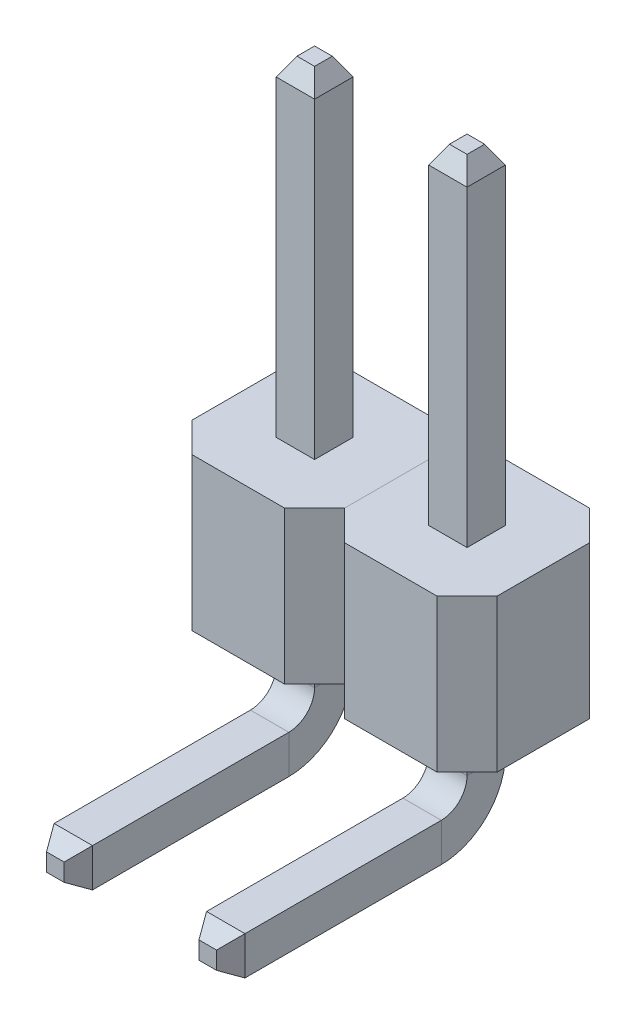
from build123d import *

# Parameters (mm, degrees)
SKETCH1_W             = 2.54
SKETCH1_H             = 2.54
BOSS_EXTRUDE1_DEPTH   = 2.54
CHAMFER1_SIZE         = 0.5
SKETCH3_W             = 0.64
SKETCH3_H             = 0.64
CHAMFER2_SIZE         = 0.3
CHAMFER2_SIZE2        = 0.173205081
CHAMFER2_PART_2_SIZE  = 0.3
CHAMFER2_PART_2_SIZE2 = 0.173205081
CHAMFER2_PART_3_SIZE  = 0.3
CHAMFER2_PART_3_SIZE2 = 0.173205081
CHAMFER2_PART_4_SIZE  = 0.3
CHAMFER2_PART_4_SIZE2 = 0.173205081
CHAMFER2_PART_5_SIZE  = 0.3
CHAMFER2_PART_5_SIZE2 = 0.173205081
CHAMFER2_PART_6_SIZE  = 0.3
CHAMFER2_PART_6_SIZE2 = 0.173205081
CHAMFER2_PART_7_SIZE  = 0.3
CHAMFER2_PART_7_SIZE2 = 0.173205081
CHAMFER2_PART_8_SIZE  = 0.3
CHAMFER2_PART_8_SIZE2 = 0.173205081
LPATTERN1_COUNT       = 2
LPATTERN1_PITCH       = 2.54


with BuildPart() as part:
    # Sketch1 → Boss-Extrude1 (new body)
    with BuildSketch(Plane(origin=(0, 0, 0), x_dir=(1, 0, 0), z_dir=(0, 1, 0))):
        Rectangle(SKETCH1_W, SKETCH1_H)
    extrude(amount=BOSS_EXTRUDE1_DEPTH)

    # Chamfer1
    chamfer1_edges = [part.edges().sort_by_distance(p)[0] for p in [
        (1.27, 1.27, 1.27),
        (-1.27, 1.27, 1.27),
        (-1.27, 1.27, -1.27),
        (1.27, 1.27, -1.27),
    ]]
    chamfer(chamfer1_edges, length=CHAMFER1_SIZE)

    # Sweep1: sweep along a path in Sketch2
    with BuildLine(Plane(origin=(0, 0, 0), x_dir=(0, 0, -1), z_dir=(1, 0, 0))) as sweep1_path:
        Line((0, 8.04), (0, -0.75))
        ThreePointArc((0, -0.75), (-0.219669914, -1.280330086), (-0.75, -1.5))
        Line((-0.75, -1.5), (-4.32, -1.5))
    # Sketch3 → Sweep1 (sweep)
    with BuildSketch(Plane(origin=(0, 0, 0), x_dir=(1, 0, 0), z_dir=(0, 1, 0))):
        Rectangle(SKETCH3_W, SKETCH3_H)
    sweep(path=sweep1_path.line)

    # Chamfer2
    chamfer2_edges = [part.edges().sort_by_distance(p)[0] for p in [
        (0.32, 8.04, 0),
    ]]
    chamfer2_side = [part.faces().sort_by_distance(p)[0] for p in [
        (0.32, 5.29, 0),
    ]]
    chamfer(chamfer2_edges, length=CHAMFER2_SIZE, length2=CHAMFER2_SIZE2, reference=chamfer2_side[0])

    # Chamfer2 part 2
    chamfer2_part_2_edges = [part.edges().sort_by_distance(p)[0] for p in [
        (0, 8.04, -0.32),
    ]]
    chamfer2_part_2_side = [part.faces().sort_by_distance(p)[0] for p in [
        (0, 5.29, -0.32),
    ]]
    chamfer(chamfer2_part_2_edges, length=CHAMFER2_PART_2_SIZE, length2=CHAMFER2_PART_2_SIZE2, reference=chamfer2_part_2_side[0])

    # Chamfer2 part 3
    chamfer2_part_3_edges = [part.edges().sort_by_distance(p)[0] for p in [
        (-0.32, 8.04, 0),
    ]]
    chamfer2_part_3_side = [part.faces().sort_by_distance(p)[0] for p in [
        (-0.32, 5.29, 0),
    ]]
    chamfer(chamfer2_part_3_edges, length=CHAMFER2_PART_3_SIZE, length2=CHAMFER2_PART_3_SIZE2, reference=chamfer2_part_3_side[0])

    # Chamfer2 part 4
    chamfer2_part_4_edges = [part.edges().sort_by_distance(p)[0] for p in [
        (0, 8.04, 0.32),
    ]]
    chamfer2_part_4_side = [part.faces().sort_by_distance(p)[0] for p in [
        (0, 5.29, 0.32),
    ]]
    chamfer(chamfer2_part_4_edges, length=CHAMFER2_PART_4_SIZE, length2=CHAMFER2_PART_4_SIZE2, reference=chamfer2_part_4_side[0])

    # Chamfer2 part 5
    chamfer2_part_5_edges = [part.edges().sort_by_distance(p)[0] for p in [
        (0.32, -1.5, 4.32),
    ]]
    chamfer2_part_5_side = [part.faces().sort_by_distance(p)[0] for p in [
        (0.32, -1.294348927, 1.698203794),
    ]]
    chamfer(chamfer2_part_5_edges, length=CHAMFER2_PART_5_SIZE, length2=CHAMFER2_PART_5_SIZE2, reference=chamfer2_part_5_side[0])

    # Chamfer2 part 6
    chamfer2_part_6_edges = [part.edges().sort_by_distance(p)[0] for p in [
        (0, -1.82, 4.32),
    ]]
    chamfer2_part_6_side = [part.faces().sort_by_distance(p)[0] for p in [
        (0, -1.82, 2.535),
    ]]
    chamfer(chamfer2_part_6_edges, length=CHAMFER2_PART_6_SIZE, length2=CHAMFER2_PART_6_SIZE2, reference=chamfer2_part_6_side[0])

    # Chamfer2 part 7
    chamfer2_part_7_edges = [part.edges().sort_by_distance(p)[0] for p in [
        (-0.32, -1.5, 4.32),
    ]]
    chamfer2_part_7_side = [part.faces().sort_by_distance(p)[0] for p in [
        (-0.32, -1.294348927, 1.698203794),
    ]]
    chamfer(chamfer2_part_7_edges, length=CHAMFER2_PART_7_SIZE, length2=CHAMFER2_PART_7_SIZE2, reference=chamfer2_part_7_side[0])

    # Chamfer2 part 8
    chamfer2_part_8_edges = [part.edges().sort_by_distance(p)[0] for p in [
        (0, -1.18, 4.32),
    ]]
    chamfer2_part_8_side = [part.faces().sort_by_distance(p)[0] for p in [
        (0, -1.18, 2.535),
    ]]
    chamfer(chamfer2_part_8_edges, length=CHAMFER2_PART_8_SIZE, length2=CHAMFER2_PART_8_SIZE2, reference=chamfer2_part_8_side[0])


with BuildPart() as lpattern1_1:
    # LPattern1: pattern copy
    add(part.part.moved(Location(Vector(1, 0, 0) * (1 * LPATTERN1_PITCH))))


solid = Compound([part.part, lpattern1_1.part])
